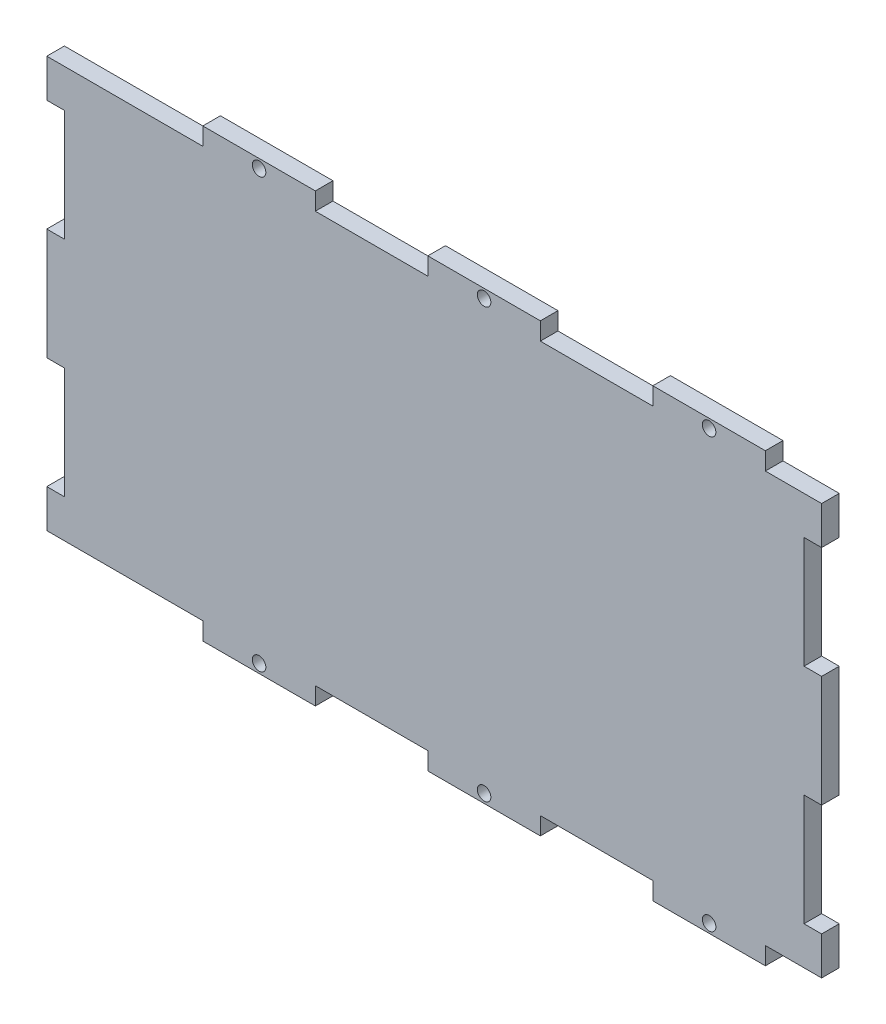
from build123d import *

# Parameters (mm, degrees)
CROQUIS1_W                = 115
CROQUIS1_H                = 70
SALIENTE_EXTRUIR1_DEPTH   = 1.5
CROQUIS2_W                = 19.166666667
CROQUIS2_H                = 3
CROQUIS2_R                = 1.15
SALIENTE_EXTRUIR2_DEPTH   = 1.5
MATRIZL1_COUNT            = 3
MATRIZL1_PITCH            = 38.333333333
SIMETR_A1_COPY_1_SKETCH_W = 19.166666667
SIMETR_A1_COPY_1_SKETCH_H = 3
SIMETR_A1_COPY_1_SKETCH_R = 1.15
SIMETR_A1_COPY_1_DEPTH    = 1.5
SIMETR_A1_COPY_2_SKETCH_W = 19.166666667
SIMETR_A1_COPY_2_SKETCH_H = 3
SIMETR_A1_COPY_2_SKETCH_R = 1.15
SIMETR_A1_COPY_2_DEPTH    = 1.5
CORTAR_EXTRUIR1_DEPTH     = 2.5
MATRIZL2_COUNT            = 2
MATRIZL2_PITCH            = 38
SIMETR_A2_COPY_1_DEPTH    = 2.5
CROQUIS4_W                = 3
CROQUIS4_H                = 6.5
CROQUIS4_H_2              = 19
SALIENTE_EXTRUIR3_DEPTH   = 17
CROQUIS5_W                = 3
CROQUIS5_H                = 19
SALIENTE_EXTRUIR4_DEPTH   = 17


with BuildPart() as part:
    # Croquis1 → Saliente-Extruir1 (new body, symmetric)
    with BuildSketch(Plane.XY):
        Rectangle(CROQUIS1_W, CROQUIS1_H)
    extrude(amount=SALIENTE_EXTRUIR1_DEPTH, both=True)

    # Croquis2 → Saliente-Extruir2 (add, symmetric)
    with BuildSketch(Plane.XY):
        with Locations((-38.333333334, 36.5)):
            Rectangle(CROQUIS2_W, CROQUIS2_H)
        with Locations((-38.333333333, 36.5)):
            Circle(CROQUIS2_R, mode=Mode.SUBTRACT)
    saliente_extruir2 = extrude(amount=SALIENTE_EXTRUIR2_DEPTH, both=True)

    # MatrizL1: Saliente-Extruir2 ×3
    with Locations(*[(i * MATRIZL1_PITCH, 0, 0) for i in range(1, MATRIZL1_COUNT)]):
        add(saliente_extruir2)

    # Simetría1: Saliente-Extruir2 across plane
    add(saliente_extruir2.mirror(Plane.ZX))

    # Simetría1 copy 1 sketch → Simetría1 copy 1 (add, symmetric)
    with BuildSketch(Plane(origin=(38.333333333, 0, 0), x_dir=(1, 0, 0), z_dir=(0, 0, 1))):
        with Locations((-38.333333334, -36.5)):
            Rectangle(SIMETR_A1_COPY_1_SKETCH_W, SIMETR_A1_COPY_1_SKETCH_H)
        with Locations((-38.333333333, -36.5)):
            Circle(SIMETR_A1_COPY_1_SKETCH_R, mode=Mode.SUBTRACT)
    extrude(amount=SIMETR_A1_COPY_1_DEPTH, both=True)

    # Simetría1 copy 2 sketch → Simetría1 copy 2 (add, symmetric)
    with BuildSketch(Plane(origin=(76.666666667, 0, 0), x_dir=(1, 0, 0), z_dir=(0, 0, 1))):
        with Locations((-38.333333334, -36.5)):
            Rectangle(SIMETR_A1_COPY_2_SKETCH_W, SIMETR_A1_COPY_2_SKETCH_H)
        with Locations((-38.333333333, -36.5)):
            Circle(SIMETR_A1_COPY_2_SKETCH_R, mode=Mode.SUBTRACT)
    extrude(amount=SIMETR_A1_COPY_2_DEPTH, both=True)

    # Croquis3 → Cortar-Extruir1 (cut, symmetric)
    with BuildSketch(Plane.XY):
        Polygon((57.5, 28.5), (54.5, 28.5), (54.5, 20.15), (54.5, 17.85), (54.5, 9.5), (57.5, 9.5), align=None)
    cortar_extruir1 = extrude(amount=CORTAR_EXTRUIR1_DEPTH, both=True, mode=Mode.SUBTRACT)

    # MatrizL2: Cortar-Extruir1 ×2
    with Locations(*[(0, -i * MATRIZL2_PITCH, 0) for i in range(1, MATRIZL2_COUNT)]):
        add(cortar_extruir1, mode=Mode.SUBTRACT)

    # Simetría2: Cortar-Extruir1 across plane
    add(cortar_extruir1.mirror(Plane(origin=(0, 0, 0), x_dir=(0, 0, 1), z_dir=(1, 0, 0))), mode=Mode.SUBTRACT)

    # Simetría2 copy 1 sketch → Simetría2 copy 1 (cut, symmetric)
    with BuildSketch(Plane(origin=(0, -38, 0), x_dir=(-1, 0, 0), z_dir=(0, 0, 1))):
        Polygon((57.5, -28.5), (54.5, -28.5), (54.5, -20.15), (54.5, -17.85), (54.5, -9.5), (57.5, -9.5), align=None)
    extrude(amount=SIMETR_A2_COPY_1_DEPTH, both=True, mode=Mode.SUBTRACT)

    # Croquis4 → Saliente-Extruir3 (add)
    with BuildSketch(Plane.ZY.offset(57.5)):
        with Locations((0, -31.75)):
            Rectangle(CROQUIS4_W, CROQUIS4_H)
        with Locations((0, 31.75)):
            Rectangle(CROQUIS4_W, CROQUIS4_H)
        Rectangle(CROQUIS4_W, CROQUIS4_H_2)
    extrude(amount=SALIENTE_EXTRUIR3_DEPTH)

    # Croquis5 → Saliente-Extruir4 (add)
    with BuildSketch(Plane.ZY.offset(54.5)):
        with Locations((0, -19)):
            Rectangle(CROQUIS5_W, CROQUIS5_H)
        with Locations((0, 19)):
            Rectangle(CROQUIS5_W, CROQUIS5_H)
    extrude(amount=SALIENTE_EXTRUIR4_DEPTH)


solid = part.part
